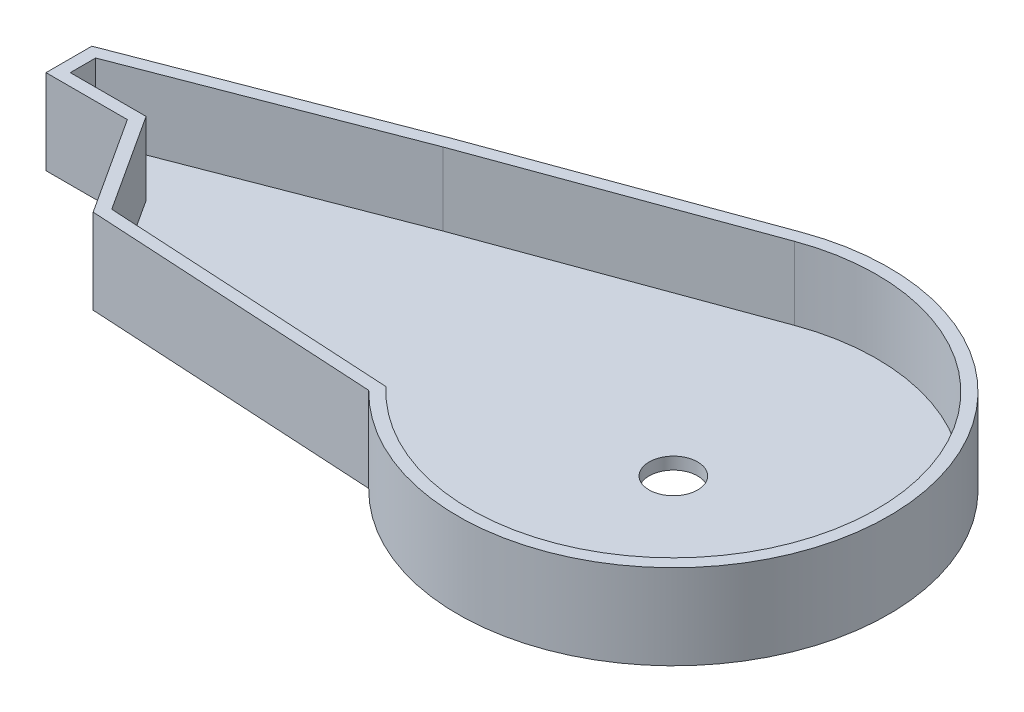
from build123d import *

# Parameters (mm, degrees)
SKETCH1_R           = 5.08
BOSS_EXTRUDE1_DEPTH = 17.78
CUT_EXTRUDE1_DEPTH  = 15.24


with BuildPart() as part:
    # Sketch1 → Boss-Extrude1 (new body)
    with BuildSketch(Plane(origin=(0, 0, 0), x_dir=(1, 0, 0), z_dir=(0, 1, 0))):
        with BuildLine():
            Line((-32.154011799, -31.603429406), (-93.281689982, -28.139023899))
            Line((-93.281689982, -28.139023899), (-106.470617871, -7.793457389))
            Line((-106.470617871, -7.793457389), (-123.496324783, -7.793457389))
            Line((-123.496324783, -7.793457389), (-123.496324783, 1.798490167))
            Line((-123.496324783, 1.798490167), (-69.358514677, 22.660976101))
            Line((-69.358514677, 22.660976101), (-15.470629933, 42.347571766))
            ThreePointArc((-15.470629933, 42.347571766), (43.979702916, -9.921842389), (-32.154011799, -31.603429406))
        make_face()
        Circle(SKETCH1_R, mode=Mode.SUBTRACT)
    extrude(amount=BOSS_EXTRUDE1_DEPTH)

    # Sketch2 → Cut-Extrude1 (cut)
    with BuildSketch(Plane(origin=(0, 17.78, 0), x_dir=(1, 0, 0), z_dir=(0, 1, 0))):
        with BuildLine():
            Line((-14.599045148, 39.961793075), (-68.465982608, 20.282849978))
            Line((-68.465982608, 20.282849978), (-120.956324783, 0.055230443))
            Line((-120.956324783, 0.055230443), (-120.956324783, -5.253457389))
            Line((-120.956324783, -5.253457389), (-105.090165624, -5.253457389))
            Line((-105.090165624, -5.253457389), (-91.851329605, -25.676013414))
            Line((-91.851329605, -25.676013414), (-31.014061001, -29.123959985))
            ThreePointArc((-31.014061001, -29.123959985), (41.392622315, -9.835031413), (-14.599045148, 39.961793075))
        make_face()
    extrude(amount=-CUT_EXTRUDE1_DEPTH, mode=Mode.SUBTRACT)


solid = part.part
